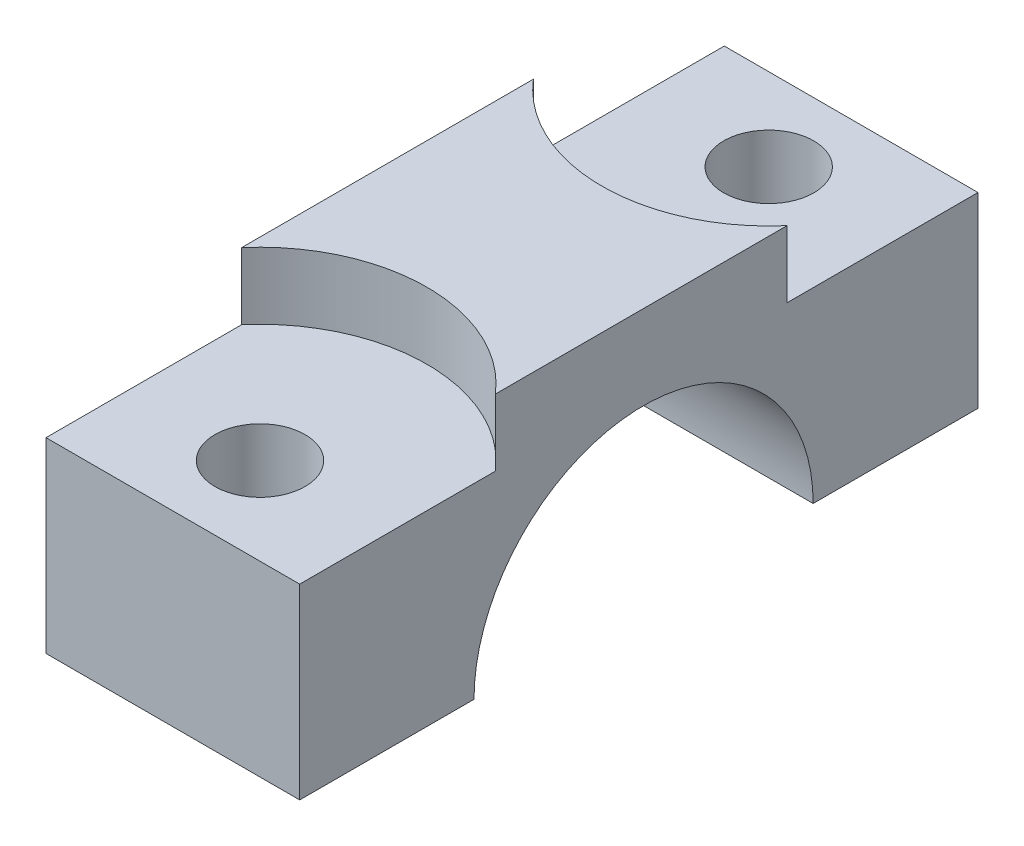
from build123d import *

# Parameters (mm, degrees)
BOSS_EXTRU_1_DEPTH                                 = 9.5
CHAMBRAGE_POUR_VIS_T_TE_HEXAGONALE_M12_D           = 6.75
CHAMBRAGE_POUR_VIS_T_TE_HEXAGONALE_M12_CBORE_D     = 25
CHAMBRAGE_POUR_VIS_T_TE_HEXAGONALE_M12_CBORE_DEPTH = 5


with BuildPart() as part:
    # Esquisse1 → Boss.-Extru.1 (new body, symmetric)
    with BuildSketch(Plane(origin=(0, 0, 0), x_dir=(0, 0, -1), z_dir=(1, 0, 0))):
        with BuildLine():
            Line((25.045581395, 19), (-25.754418605, 19))
            Line((-25.754418605, 19), (-25.754418605, 0))
            Line((-25.754418605, 0), (-12.7, 0))
            ThreePointArc((-12.7, 0), (0, 12.7), (12.7, 0))
            Line((12.7, 0), (25.045581395, 0))
            Line((25.045581395, 0), (25.045581395, 19))
        make_face()
    extrude(amount=BOSS_EXTRU_1_DEPTH, both=True)

    # Chambrage pour vis à tête hexagonale M123 (through all)
    with Locations(Plane(origin=(0, 19, 19.227209302), x_dir=(0, 0, 1), z_dir=(0, 1, 0))):
        with Locations((0, 0), (-38.1, 0)):
            CounterBoreHole(CHAMBRAGE_POUR_VIS_T_TE_HEXAGONALE_M12_D / 2, CHAMBRAGE_POUR_VIS_T_TE_HEXAGONALE_M12_CBORE_D / 2, CHAMBRAGE_POUR_VIS_T_TE_HEXAGONALE_M12_CBORE_DEPTH)


solid = part.part
